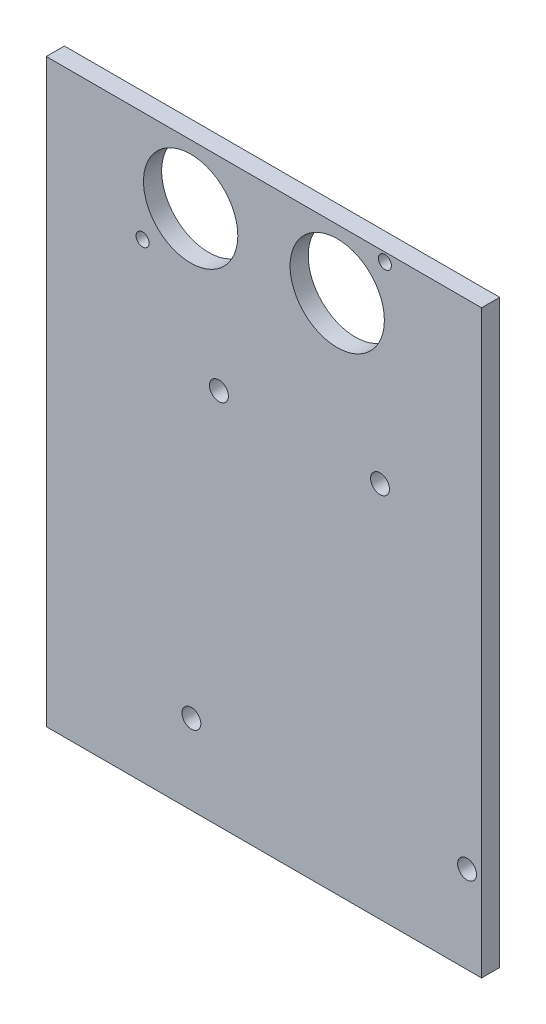
from build123d import *

# Parameters (mm, degrees)
SKETCH2_W           = 76.2
SKETCH2_H           = 101.6
BOSS_EXTRUDE1_DEPTH = 3.175
SKETCH3_R           = 8.255
SKETCH3_R_2         = 1.143
CUT_EXTRUDE1_DEPTH  = 3.175
SKETCH6_R           = 1.651
CUT_EXTRUDE2_DEPTH  = 3.175


with BuildPart() as part:
    # Sketch2 → Boss-Extrude1 (new body)
    with BuildSketch(Plane.XY):
        with Locations((38.1, 50.8)):
            Rectangle(SKETCH2_W, SKETCH2_H)
    extrude(amount=BOSS_EXTRUDE1_DEPTH)

    # Sketch3 → Cut-Extrude1 (cut)
    with BuildSketch(Plane.XY.offset(3.175)):
        with Locations((25.273, 91.186)):
            Circle(SKETCH3_R)
        with Locations((50.927, 91.186)):
            Circle(SKETCH3_R)
        with Locations((59.269530294, 100.076)):
            Circle(SKETCH3_R_2)
        with Locations((16.851530294, 82.296)):
            Circle(SKETCH3_R_2)
    extrude(amount=-CUT_EXTRUDE1_DEPTH, mode=Mode.SUBTRACT)

    # Sketch6 → Cut-Extrude2 (cut)
    with BuildSketch(Plane(origin=(0, 0, 0), x_dir=(-1, 0, 0), z_dir=(0, 0, -1))):
        with Locations((-73.66, 15.24)):
            Circle(SKETCH6_R)
        with Locations((-25.4, 13.97)):
            Circle(SKETCH6_R)
        with Locations((-30.226, 66.04)):
            Circle(SKETCH6_R)
        with Locations((-58.42, 66.04)):
            Circle(SKETCH6_R)
    extrude(amount=-CUT_EXTRUDE2_DEPTH, mode=Mode.SUBTRACT)


solid = part.part
